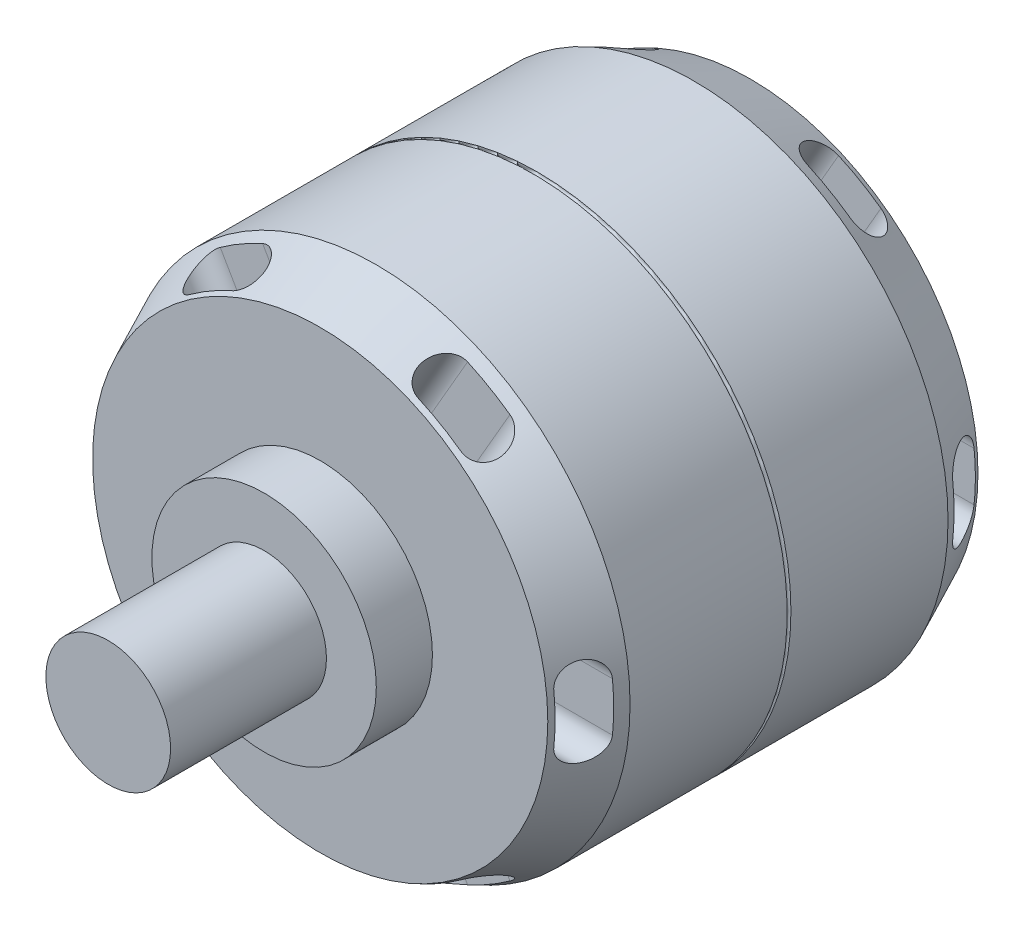
from build123d import *
from build123d.topology import SkipClean

# Parameters (mm, degrees)
SKETCH1_R               = 40.7
BOSS_EXTRUDE1_DEPTH     = 51
SKETCH3_R               = 40.7
BOSS_EXTRUDE2_DEPTH     = 9
BOSS_EXTRUDE2_TAPER     = 25
CUT_EXTRUDE1_DEPTH      = 84.144332338
CIRPATTERN1_COUNT       = 6
MIRROR1_COPY_1_SKETCH_R = 40.7
MIRROR1_COPY_1_DEPTH    = 9
MIRROR1_COPY_1_TAPER    = 25
MIRROR1_COPY_2_SKETCH_R = 40.7
MIRROR1_COPY_2_DEPTH    = 9
MIRROR1_COPY_2_TAPER    = 25
MIRROR1_COPY_3_SKETCH_R = 40.7
MIRROR1_COPY_3_DEPTH    = 9
MIRROR1_COPY_3_TAPER    = 25
MIRROR1_COPY_4_SKETCH_R = 40.7
MIRROR1_COPY_4_DEPTH    = 9
MIRROR1_COPY_4_TAPER    = 25
MIRROR1_COPY_5_SKETCH_R = 40.7
MIRROR1_COPY_5_DEPTH    = 9
MIRROR1_COPY_5_TAPER    = 25
MIRROR1_COPY_6_DEPTH    = 84.144332338
MIRROR1_COPY_7_DEPTH    = 84.144332338
MIRROR1_COPY_8_DEPTH    = 84.144332338
MIRROR1_COPY_9_DEPTH    = 84.144332338
MIRROR1_COPY_10_DEPTH   = 84.144332338
SKETCH6_R               = 0.3
SKETCH5_R               = 18
BOSS_EXTRUDE3_DEPTH     = 9
SKETCH7_R               = 10
BOSS_EXTRUDE4_DEPTH     = 25


with BuildPart() as part:
    # Sketch1 → Boss-Extrude1 (new body)
    with BuildSketch(Plane.XY):
        Circle(SKETCH1_R)
    extrude(amount=BOSS_EXTRUDE1_DEPTH)

    # Sketch3 → Boss-Extrude2 (add)
    with BuildSketch(Plane.XY.offset(51)):
        Circle(SKETCH3_R)
    boss_extrude2 = extrude(amount=BOSS_EXTRUDE2_DEPTH, taper=BOSS_EXTRUDE2_TAPER)

    # Sketch4 → Cut-Extrude1 (cut, symmetric)
    with BuildSketch(Plane(origin=(0, 0, 0), x_dir=(0, 0, -1), z_dir=(1, 0, 0))):
        with BuildLine():
            Line((-52.797564874, 3.924171003), (-52.797564874, -3.924171003))
            ThreePointArc((-52.797564874, -3.924171003), (-56, -7.126606129), (-59.202435126, -3.924171003))
            Line((-59.202435126, -3.924171003), (-59.202435126, 3.924171003))
            ThreePointArc((-59.202435126, 3.924171003), (-56, 7.126606129), (-52.797564874, 3.924171003))
        make_face()
    cut_extrude1 = extrude(amount=CUT_EXTRUDE1_DEPTH, both=True, mode=Mode.SUBTRACT)

    # CirPattern1: Boss-Extrude2, Cut-Extrude1 ×6 about axis
    cirpattern1_axis = Axis((0, 0, 52.797564874), (0, 0, -1))
    add([boss_extrude2.rotate(cirpattern1_axis, i * 360 / CIRPATTERN1_COUNT) for i in range(1, CIRPATTERN1_COUNT)])
    add([cut_extrude1.rotate(cirpattern1_axis, i * 360 / CIRPATTERN1_COUNT) for i in range(1, CIRPATTERN1_COUNT)], mode=Mode.SUBTRACT)

    # Mirror1: Boss-Extrude2, Cut-Extrude1 across plane
    add(boss_extrude2.mirror(Plane.XY.offset(25.5)))
    add(cut_extrude1.mirror(Plane.XY.offset(25.5)), mode=Mode.SUBTRACT)

    # Mirror1 copy 1 sketch → Mirror1 copy 1 (add)
    with SkipClean():  # the faces are left unmerged after this step: merging them gives an invalid solid
        with BuildSketch(Plane(origin=(0, 0, 0), x_dir=(0.5000000000000001, -0.8660254037844386, 0), z_dir=(0, 0, -1))):
            Circle(MIRROR1_COPY_1_SKETCH_R)
        extrude(amount=MIRROR1_COPY_1_DEPTH, taper=MIRROR1_COPY_1_TAPER)

    # Mirror1 copy 2 sketch → Mirror1 copy 2 (add)
    with SkipClean():  # the faces are left unmerged after this step: merging them gives an invalid solid
        with BuildSketch(Plane(origin=(0, 0, 0), x_dir=(-0.4999999999999998, -0.8660254037844387, 0), z_dir=(0, 0, -1))):
            Circle(MIRROR1_COPY_2_SKETCH_R)
        extrude(amount=MIRROR1_COPY_2_DEPTH, taper=MIRROR1_COPY_2_TAPER)

    # Mirror1 copy 3 sketch → Mirror1 copy 3 (add)
    with SkipClean():  # the faces are left unmerged after this step: merging them gives an invalid solid
        with BuildSketch(Plane(origin=(0, 0, 0), x_dir=(-1, 0, 0), z_dir=(0, 0, -1))):
            Circle(MIRROR1_COPY_3_SKETCH_R)
        extrude(amount=MIRROR1_COPY_3_DEPTH, taper=MIRROR1_COPY_3_TAPER)

    # Mirror1 copy 4 sketch → Mirror1 copy 4 (add)
    with SkipClean():  # the faces are left unmerged after this step: merging them gives an invalid solid
        with BuildSketch(Plane(origin=(0, 0, 0), x_dir=(-0.5000000000000004, 0.8660254037844384, 0), z_dir=(0, 0, -1))):
            Circle(MIRROR1_COPY_4_SKETCH_R)
        extrude(amount=MIRROR1_COPY_4_DEPTH, taper=MIRROR1_COPY_4_TAPER)

    # Mirror1 copy 5 sketch → Mirror1 copy 5 (add)
    with SkipClean():  # the faces are left unmerged after this step: merging them gives an invalid solid
        with BuildSketch(Plane(origin=(0, 0, 0), x_dir=(0.5000000000000001, 0.8660254037844386, 0), z_dir=(0, 0, -1))):
            Circle(MIRROR1_COPY_5_SKETCH_R)
        extrude(amount=MIRROR1_COPY_5_DEPTH, taper=MIRROR1_COPY_5_TAPER)

    # Mirror1 copy 6 sketch → Mirror1 copy 6 (cut, symmetric)
    with SkipClean():  # the faces are left unmerged after this step: merging them gives an invalid solid
        with BuildSketch(Plane(origin=(0, 0, 51), x_dir=(0, 0, 1), z_dir=(0.5000000000000001, -0.8660254037844386, 0))):
            with BuildLine():
                Line((-52.797564874, -3.924171003), (-52.797564874, 3.924171003))
                ThreePointArc((-52.797564874, 3.924171003), (-56, 7.126606129), (-59.202435126, 3.924171003))
                Line((-59.202435126, 3.924171003), (-59.202435126, -3.924171003))
                ThreePointArc((-59.202435126, -3.924171003), (-56, -7.126606129), (-52.797564874, -3.924171003))
            make_face()
        extrude(amount=MIRROR1_COPY_6_DEPTH, both=True, mode=Mode.SUBTRACT)

    # Mirror1 copy 7 sketch → Mirror1 copy 7 (cut, symmetric)
    with SkipClean():  # the faces are left unmerged after this step: merging them gives an invalid solid
        with BuildSketch(Plane(origin=(0, 0, 51), x_dir=(0, 0, 1), z_dir=(-0.4999999999999998, -0.8660254037844387, 0))):
            with BuildLine():
                Line((-52.797564874, -3.924171003), (-52.797564874, 3.924171003))
                ThreePointArc((-52.797564874, 3.924171003), (-56, 7.126606129), (-59.202435126, 3.924171003))
                Line((-59.202435126, 3.924171003), (-59.202435126, -3.924171003))
                ThreePointArc((-59.202435126, -3.924171003), (-56, -7.126606129), (-52.797564874, -3.924171003))
            make_face()
        extrude(amount=MIRROR1_COPY_7_DEPTH, both=True, mode=Mode.SUBTRACT)

    # Mirror1 copy 8 sketch → Mirror1 copy 8 (cut, symmetric)
    with BuildSketch(Plane(origin=(0, 0, 51), x_dir=(0, 0, 1), z_dir=(-1, 0, 0))):
        with BuildLine():
            Line((-52.797564874, -3.924171003), (-52.797564874, 3.924171003))
            ThreePointArc((-52.797564874, 3.924171003), (-56, 7.126606129), (-59.202435126, 3.924171003))
            Line((-59.202435126, 3.924171003), (-59.202435126, -3.924171003))
            ThreePointArc((-59.202435126, -3.924171003), (-56, -7.126606129), (-52.797564874, -3.924171003))
        make_face()
    extrude(amount=MIRROR1_COPY_8_DEPTH, both=True, mode=Mode.SUBTRACT)

    # Mirror1 copy 9 sketch → Mirror1 copy 9 (cut, symmetric)
    with BuildSketch(Plane(origin=(0, 0, 51), x_dir=(0, 0, 1), z_dir=(-0.5000000000000004, 0.8660254037844384, 0))):
        with BuildLine():
            Line((-52.797564874, -3.924171003), (-52.797564874, 3.924171003))
            ThreePointArc((-52.797564874, 3.924171003), (-56, 7.126606129), (-59.202435126, 3.924171003))
            Line((-59.202435126, 3.924171003), (-59.202435126, -3.924171003))
            ThreePointArc((-59.202435126, -3.924171003), (-56, -7.126606129), (-52.797564874, -3.924171003))
        make_face()
    extrude(amount=MIRROR1_COPY_9_DEPTH, both=True, mode=Mode.SUBTRACT)

    # Mirror1 copy 10 sketch → Mirror1 copy 10 (cut, symmetric)
    with BuildSketch(Plane(origin=(0, 0, 51), x_dir=(0, 0, 1), z_dir=(0.5000000000000001, 0.8660254037844386, 0))):
        with BuildLine():
            Line((-52.797564874, -3.924171003), (-52.797564874, 3.924171003))
            ThreePointArc((-52.797564874, 3.924171003), (-56, 7.126606129), (-59.202435126, 3.924171003))
            Line((-59.202435126, 3.924171003), (-59.202435126, -3.924171003))
            ThreePointArc((-59.202435126, -3.924171003), (-56, -7.126606129), (-52.797564874, -3.924171003))
        make_face()
    extrude(amount=MIRROR1_COPY_10_DEPTH, both=True, mode=Mode.SUBTRACT)

    # Sketch6 → Cut-Revolve1 (revolve, cut)
    with BuildSketch(Plane(origin=(0, 0, 0), x_dir=(0, 0, -1), z_dir=(1, 0, 0)), mode=Mode.PRIVATE) as cut_revolve1_sk:
        with Locations((-25.5, -40.7)):
            Circle(SKETCH6_R)
    revolve(cut_revolve1_sk.sketch.rotate(Axis((0, 0, 0), (0, 0, 1)), 270), axis=Axis((0, 0, 0), (0, 0, 1)), mode=Mode.SUBTRACT)

    # Sketch5 → Boss-Extrude3 (add)
    with BuildSketch(Plane.XY.offset(60)):
        Circle(SKETCH5_R)
    extrude(amount=BOSS_EXTRUDE3_DEPTH)

    # Sketch7 → Boss-Extrude4 (add)
    with BuildSketch(Plane.XY.offset(69)):
        Circle(SKETCH7_R)
    extrude(amount=BOSS_EXTRUDE4_DEPTH)


solid = part.part
